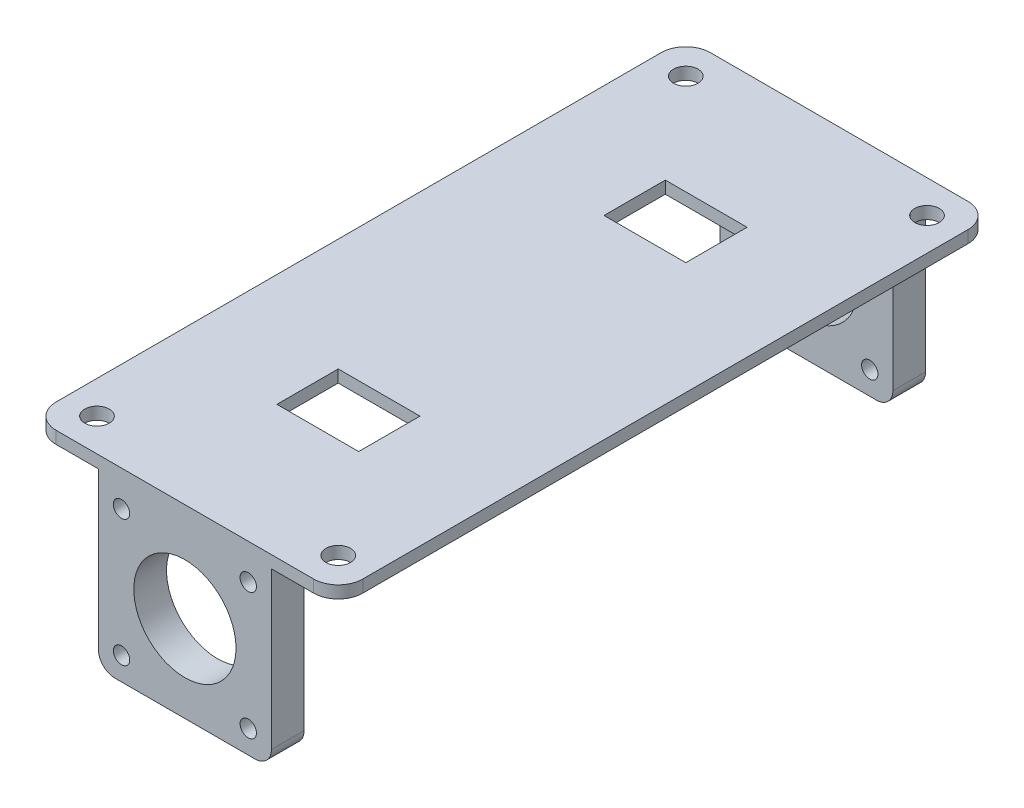
from build123d import *

# Parameters (mm, degrees)
CROQUIS1_W              = 42.3
CROQUIS1_H              = 42.3
CROQUIS1_R              = 12.5
CROQUIS1_R_2            = 2
SALIENTE_EXTRUIR2_DEPTH = 8
CROQUIS3_W              = 75
CROQUIS3_H              = 80
CROQUIS3_R              = 3
CROQUIS3_W_2            = 20
CROQUIS3_H_2            = 15
SALIENTE_EXTRUIR3_DEPTH = 3
REDONDEO1_R             = 4
REDONDEO3_R             = 6


with BuildPart() as part:
    # Croquis1 → Saliente-Extruir2 (new body)
    with BuildSketch(Plane.XY):
        Rectangle(CROQUIS1_W, CROQUIS1_H)
        Circle(CROQUIS1_R, mode=Mode.SUBTRACT)
        with Locations((-15.5, 15.5)):
            Circle(CROQUIS1_R_2, mode=Mode.SUBTRACT)
        with Locations((15.5, 15.5)):
            Circle(CROQUIS1_R_2, mode=Mode.SUBTRACT)
        with Locations((15.5, -15.5)):
            Circle(CROQUIS1_R_2, mode=Mode.SUBTRACT)
        with Locations((-15.5, -15.5)):
            Circle(CROQUIS1_R_2, mode=Mode.SUBTRACT)
    saliente_extruir2 = extrude(amount=SALIENTE_EXTRUIR2_DEPTH)

    # Croquis3 → Saliente-Extruir3 (add)
    with BuildSketch(Plane(origin=(0, 21.15, 0), x_dir=(1, 0, 0), z_dir=(0, 1, 0))):
        with Locations((0, 32)):
            Rectangle(CROQUIS3_W, CROQUIS3_H)
        with Locations((-29.5, 0)):
            Circle(CROQUIS3_R, mode=Mode.SUBTRACT)
        with Locations((29.5, 0)):
            Circle(CROQUIS3_R, mode=Mode.SUBTRACT)
        with Locations((0, 32)):
            Rectangle(CROQUIS3_W_2, CROQUIS3_H_2, mode=Mode.SUBTRACT)
    saliente_extruir3 = extrude(amount=SALIENTE_EXTRUIR3_DEPTH)

    # Simetría10: Saliente-Extruir3 across plane
    add(saliente_extruir3.mirror(Plane(origin=(0, 0, -72), x_dir=(1, 0, 0), z_dir=(0, 0, -1))))

    # Simetría12: Saliente-Extruir2 across plane
    add(saliente_extruir2.mirror(Plane(origin=(0, 0, -72), x_dir=(1, 0, 0), z_dir=(0, 0, -1))))

    # Redondeo1
    redondeo1_edges = [part.edges().sort_by_distance(p)[0] for p in [
        (21.15, -21.15, 4),
        (-21.15, -21.15, 4),
        (-21.15, -21.15, -148),
        (21.15, -21.15, -148),
    ]]
    fillet(redondeo1_edges, radius=REDONDEO1_R)

    # Redondeo3
    redondeo3_edges = [part.edges().sort_by_distance(p)[0] for p in [
        (-37.5, 22.65, 8),
        (37.5, 22.65, 8),
        (-37.5, 22.65, -152),
        (37.5, 22.65, -152),
    ]]
    fillet(redondeo3_edges, radius=REDONDEO3_R)


solid = part.part
